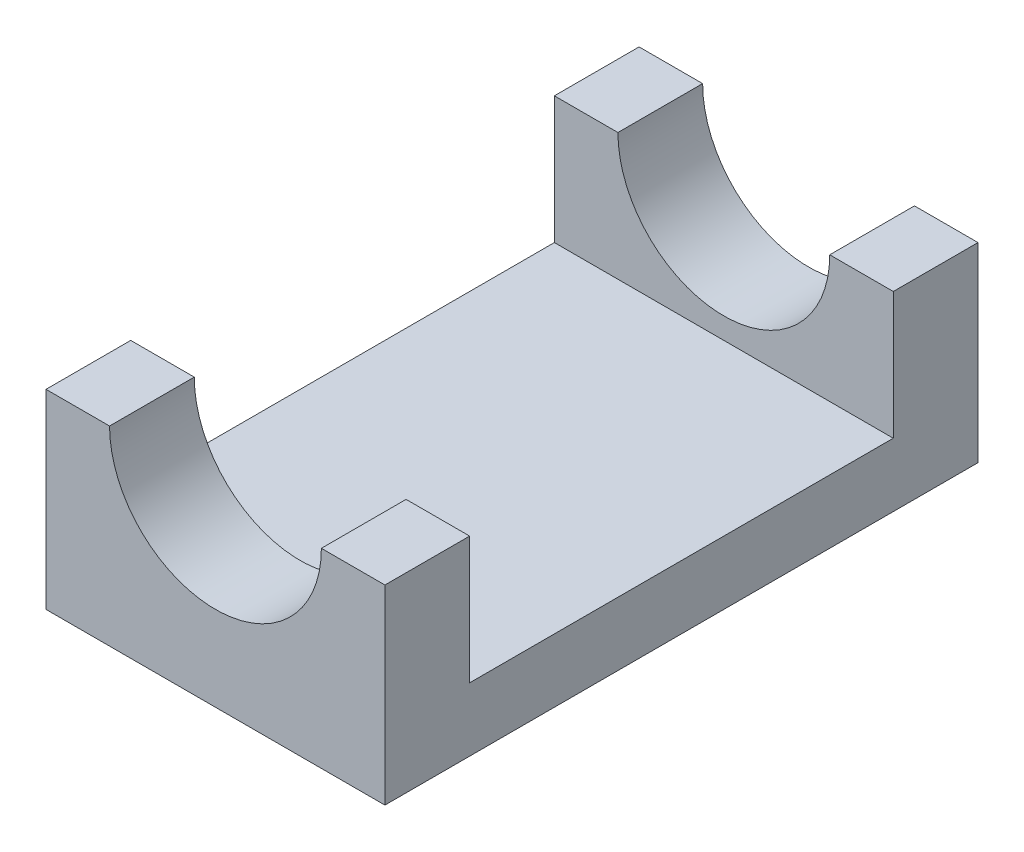
from build123d import *

# Parameters (mm, degrees)
SKETCH1_W           = 40
SKETCH1_H           = 45
BOSS_EXTRUDE1_DEPTH = 70
SKETCH2_R           = 12.5
CUT_EXTRUDE1_DEPTH  = 10
CUT_EXTRUDE2_START  = -10
SKETCH3_R           = 12.5
CUT_EXTRUDE2_DEPTH  = 10
SKETCH4_W           = 40
SKETCH4_H           = 22.5
CUT_EXTRUDE3_DEPTH  = 77.198753271
SKETCH5_W           = 40
SKETCH5_H           = 50
CUT_EXTRUDE4_DEPTH  = 15


with BuildPart() as part:
    # Sketch1 → Boss-Extrude1 (new body)
    with BuildSketch(Plane.XY):
        Rectangle(SKETCH1_W, SKETCH1_H)
    extrude(amount=BOSS_EXTRUDE1_DEPTH)

    # Sketch2 → Cut-Extrude1 (cut)
    with BuildSketch(Plane(origin=(0, 0, 0), x_dir=(-1, 0, 0), z_dir=(0, 0, -1))):
        Circle(SKETCH2_R)
    extrude(amount=-CUT_EXTRUDE1_DEPTH, mode=Mode.SUBTRACT)

    # Sketch3 → Cut-Extrude2 (cut)
    with BuildSketch(Plane.XY.offset(70).offset(CUT_EXTRUDE2_START)):
        Circle(SKETCH3_R)
    extrude(amount=CUT_EXTRUDE2_DEPTH, mode=Mode.SUBTRACT)

    # Sketch4 → Cut-Extrude3 (cut, through all)
    with BuildSketch(Plane.XY.offset(70)):
        with Locations((0, 11.25)):
            Rectangle(SKETCH4_W, SKETCH4_H)
    extrude(amount=-CUT_EXTRUDE3_DEPTH, mode=Mode.SUBTRACT)

    # Sketch5 → Cut-Extrude4 (cut)
    with BuildSketch(Plane(origin=(0, 0, 0), x_dir=(1, 0, 0), z_dir=(0, 1, 0))):
        with Locations((0, -35)):
            Rectangle(SKETCH5_W, SKETCH5_H)
    extrude(amount=-CUT_EXTRUDE4_DEPTH, mode=Mode.SUBTRACT)


solid = part.part
